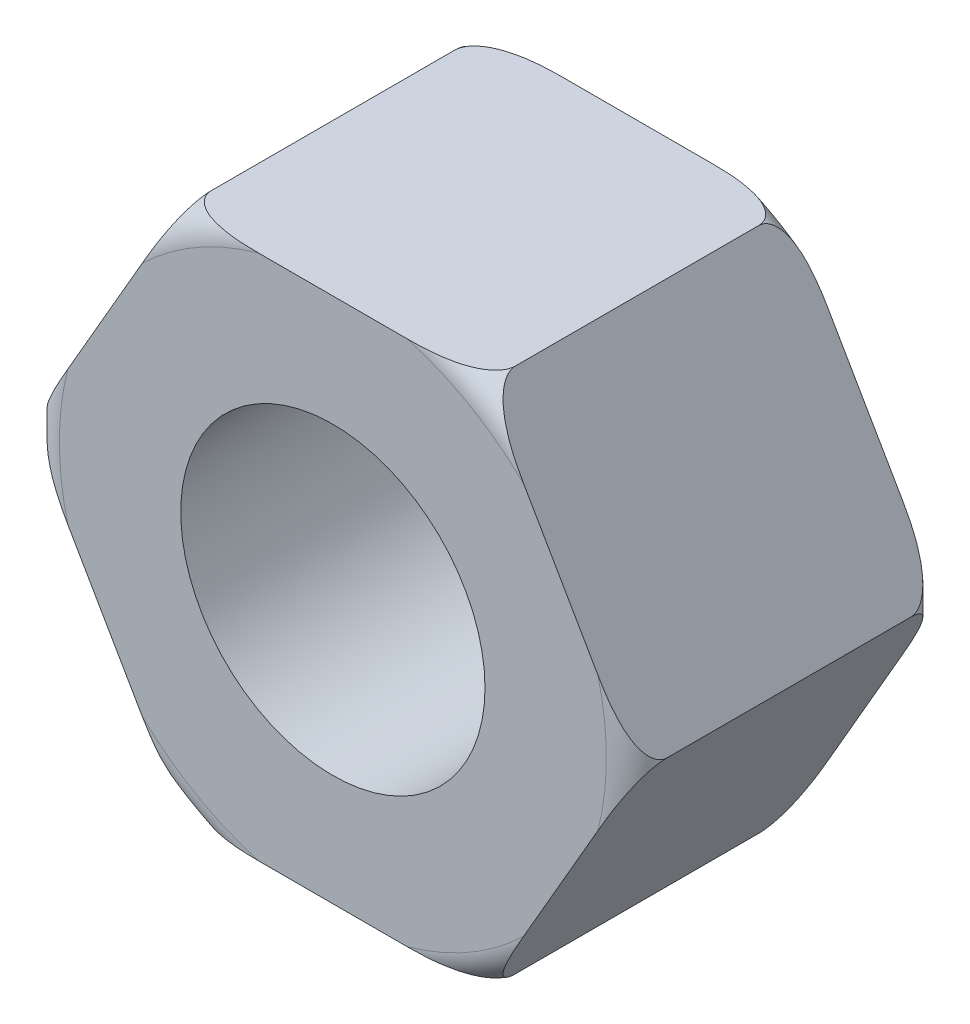
from build123d import *

# Parameters (mm, degrees)
BOSS_EXTRUDE1_DEPTH = 20
SKETCH2_R           = 10
CUT_EXTRUDE1_DEPTH  = 20


with BuildPart() as part:
    # Sketch1 → Boss-Extrude1 (new body)
    with BuildSketch(Plane.XY):
        Polygon((-19.976319314, 0), (-9.988159657, -17.3), (9.988159657, -17.3), (19.976319314, 0), (9.988159657, 17.3), (-9.988159657, 17.3), align=None)
    extrude(amount=BOSS_EXTRUDE1_DEPTH)

    # Sketch2 → Cut-Extrude1 (cut)
    with BuildSketch(Plane.XY.offset(20)):
        Circle(SKETCH2_R)
    extrude(amount=-CUT_EXTRUDE1_DEPTH, mode=Mode.SUBTRACT)

    # Sketch3 → Cut-Revolve1 (revolve, cut)
    with BuildSketch(Plane(origin=(0, 0, 0), x_dir=(1, 0, 0), z_dir=(0, 1, 0))):
        with BuildLine():
            Line((19.976319314, -2), (19.976319314, 0))
            Line((19.976319314, 0), (17.976319314, 0))
            ThreePointArc((17.976319314, 0), (19.390532876, -0.585786438), (19.976319314, -2))
        make_face()
    cut_revolve1 = revolve(axis=Axis((0, 0, 0), (0, 0, 1)), mode=Mode.SUBTRACT)

    # Mirror1: Cut-Revolve1 across plane
    add(cut_revolve1.mirror(Plane(origin=(0, 0, 10), x_dir=(1, 0, 0), z_dir=(0, 0, -1))), mode=Mode.SUBTRACT)


solid = part.part
